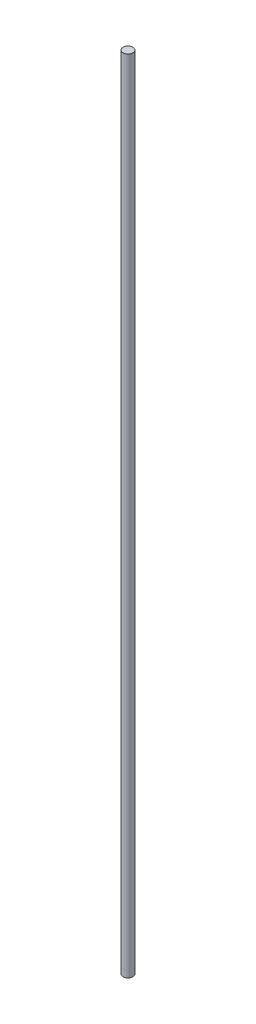
from build123d import *

# Parameters (mm, degrees)
CROQUIS1_R              = 4
SALIENTE_EXTRUIR1_DEPTH = 650


with BuildPart() as part:
    # Croquis1 → Saliente-Extruir1 (new body)
    with BuildSketch(Plane(origin=(0, 0, 0), x_dir=(1, 0, 0), z_dir=(0, 1, 0))):
        Circle(CROQUIS1_R)
    extrude(amount=SALIENTE_EXTRUIR1_DEPTH)


solid = part.part
